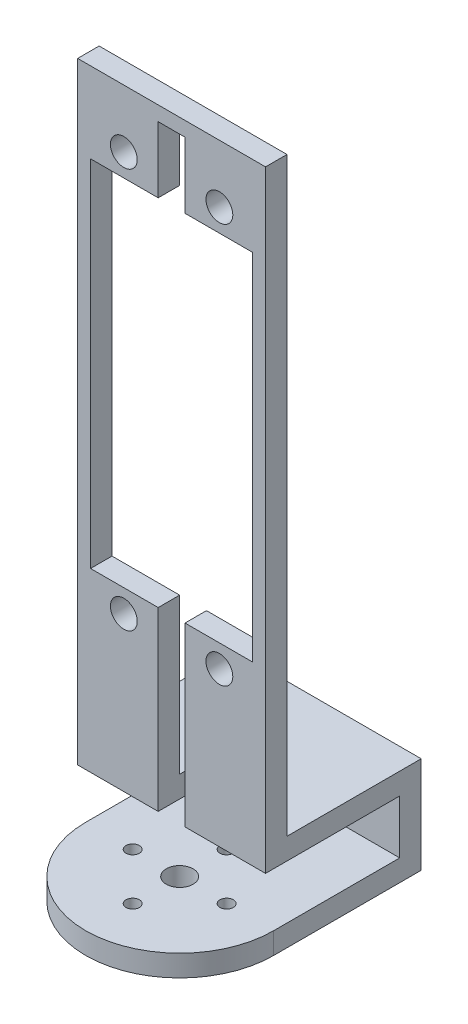
from build123d import *

# Parameters (mm, degrees)
BOSS_EXTRUDE2_DEPTH = 4
SKETCH4_W           = 35
SKETCH4_H           = 4
BOSS_EXTRUDE3_DEPTH = 10
BOSS_EXTRUDE4_DEPTH = 35
SKETCH9_R           = 2.5
CUT_EXTRUDE1_DEPTH  = 6
SKETCH10_R          = 1.25
CUT_EXTRUDE2_DEPTH  = 6
SKETCH11_R          = 2.5
CUT_EXTRUDE3_DEPTH  = 4


with BuildPart() as part:
    # Sketch3 → Boss-Extrude2 (new body)
    with BuildSketch(Plane(origin=(0, 0, 0), x_dir=(1, 0, 0), z_dir=(0, 1, 0))):
        with BuildLine():
            Line((-17.5, 0), (-17.5, 27.5))
            Line((-17.5, 27.5), (17.5, 27.5))
            Line((17.5, 27.5), (17.5, 0))
            ThreePointArc((17.5, 0), (0, -17.5), (-17.5, 0))
        make_face()
    extrude(amount=BOSS_EXTRUDE2_DEPTH)

    # Sketch4 → Boss-Extrude3 (add)
    with BuildSketch(Plane(origin=(0, 4, 0), x_dir=(1, 0, 0), z_dir=(0, 1, 0))):
        with Locations((0, 25.5)):
            Rectangle(SKETCH4_W, SKETCH4_H)
    extrude(amount=BOSS_EXTRUDE3_DEPTH)

    # Sketch6 → Boss-Extrude4 (add)
    with BuildSketch(Plane.ZY.offset(17.5)):
        Polygon((-27.5, 14), (-27.5, 18), (-2.5, 18), (-2.5, 128), (1.5, 128), (1.5, 14), align=None)
    extrude(amount=-BOSS_EXTRUDE4_DEPTH)

    # Sketch9 → Cut-Extrude1 (cut)
    with BuildSketch(Plane.XY.offset(1.5)):
        with Locations((-8.9, 117.2)):
            Circle(SKETCH9_R)
        with Locations((8.9, 117.2)):
            Circle(SKETCH9_R)
        with Locations((-8.9, 42.7)):
            Circle(SKETCH9_R)
        with Locations((8.9, 42.7)):
            Circle(SKETCH9_R)
        Polygon((-15.1, 113), (-2.5, 113), (-2.5, 125.287895972), (0, 125.287895972), (2.5, 125.287895972), (2.5, 113), (15.1, 113), (15.1, 46.9), (2.5, 46.9), (2.5, 10), (-2.5, 10), (-2.5, 46.9), (-15.1, 46.9), align=None)
    extrude(amount=-CUT_EXTRUDE1_DEPTH, mode=Mode.SUBTRACT)

    # Sketch10 → Cut-Extrude2 (cut)
    with BuildSketch(Plane.XZ):
        with Locations((-8.75, 0)):
            Circle(SKETCH10_R)
        with Locations((8.75, 0)):
            Circle(SKETCH10_R)
        with Locations((0, 8.75)):
            Circle(SKETCH10_R)
        with Locations((0, -8.75)):
            Circle(SKETCH10_R)
    extrude(amount=-CUT_EXTRUDE2_DEPTH, mode=Mode.SUBTRACT)

    # Sketch11 → Cut-Extrude3 (cut)
    with BuildSketch(Plane.XZ):
        Circle(SKETCH11_R)
    extrude(amount=-CUT_EXTRUDE3_DEPTH, mode=Mode.SUBTRACT)


solid = part.part
